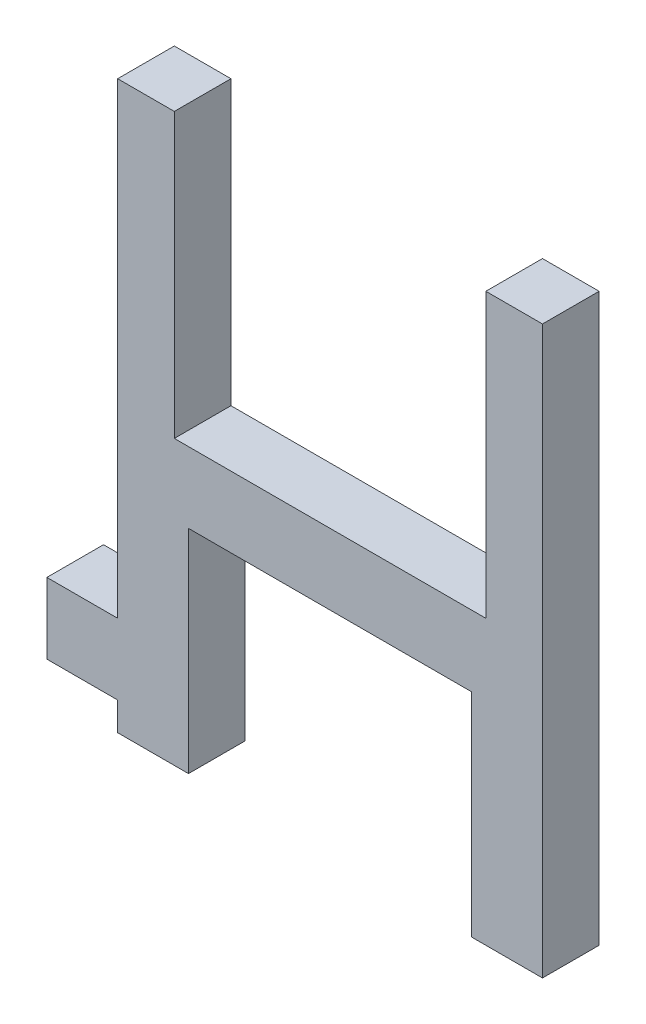
from build123d import *

# Parameters (mm, degrees)
P_IDAT_VYSUNUT_M1_DEPTH  = 4
SKICA2_W                 = 20
SKICA2_H                 = 4
P_IDAT_VYSUNUT_M2_DEPTH  = 15
SKICA3_W                 = 5.5
SKICA3_H                 = 3
ODEBRAT_VYSUNUT_M1_DEPTH = 15
SKICA4_W                 = 20
SKICA4_H                 = 15
ODEBRAT_VYSUNUT_M2_DEPTH = 15
SKICA5_W                 = 4
SKICA5_H                 = 4
P_IDAT_VYSUNUT_M3_DEPTH  = 20


with BuildPart() as part:
    # Skica1 → Přidat vysunutím1 (new body)
    with BuildSketch(Plane.XY):
        Polygon((0, 0), (5, 0), (5, -2), (10, -2), (10, 4.082474227), (10, 13), (30, 13), (30, -2), (35, -2), (35, 18), (5, 18), (5, 5), (0, 5), align=None)
    extrude(amount=P_IDAT_VYSUNUT_M1_DEPTH)

    # Skica2 → Přidat vysunutím2 (add)
    with BuildSketch(Plane(origin=(0, 18, 0), x_dir=(1, 0, 0), z_dir=(0, 1, 0))):
        with Locations((20, -2)):
            Rectangle(SKICA2_W, SKICA2_H)
    extrude(amount=P_IDAT_VYSUNUT_M2_DEPTH)

    # Skica3 → Odebrat vysunutím1 (cut)
    with BuildSketch(Plane.XY.offset(4)):
        with Locations((20, 28)):
            Rectangle(SKICA3_W, SKICA3_H)
    extrude(amount=-ODEBRAT_VYSUNUT_M1_DEPTH, mode=Mode.SUBTRACT)

    # Skica4 → Odebrat vysunutím2 (cut)
    with BuildSketch(Plane.XY.offset(4)):
        with Locations((20, 25.5)):
            Rectangle(SKICA4_W, SKICA4_H)
    extrude(amount=-ODEBRAT_VYSUNUT_M2_DEPTH, mode=Mode.SUBTRACT)

    # Skica5 → Přidat vysunutím3 (add)
    with BuildSketch(Plane(origin=(0, 18, 0), x_dir=(1, 0, 0), z_dir=(0, 1, 0))):
        with Locations((7, -2)):
            Rectangle(SKICA5_W, SKICA5_H)
        with Locations((33, -2)):
            Rectangle(SKICA5_W, SKICA5_H)
    extrude(amount=P_IDAT_VYSUNUT_M3_DEPTH)


solid = part.part
